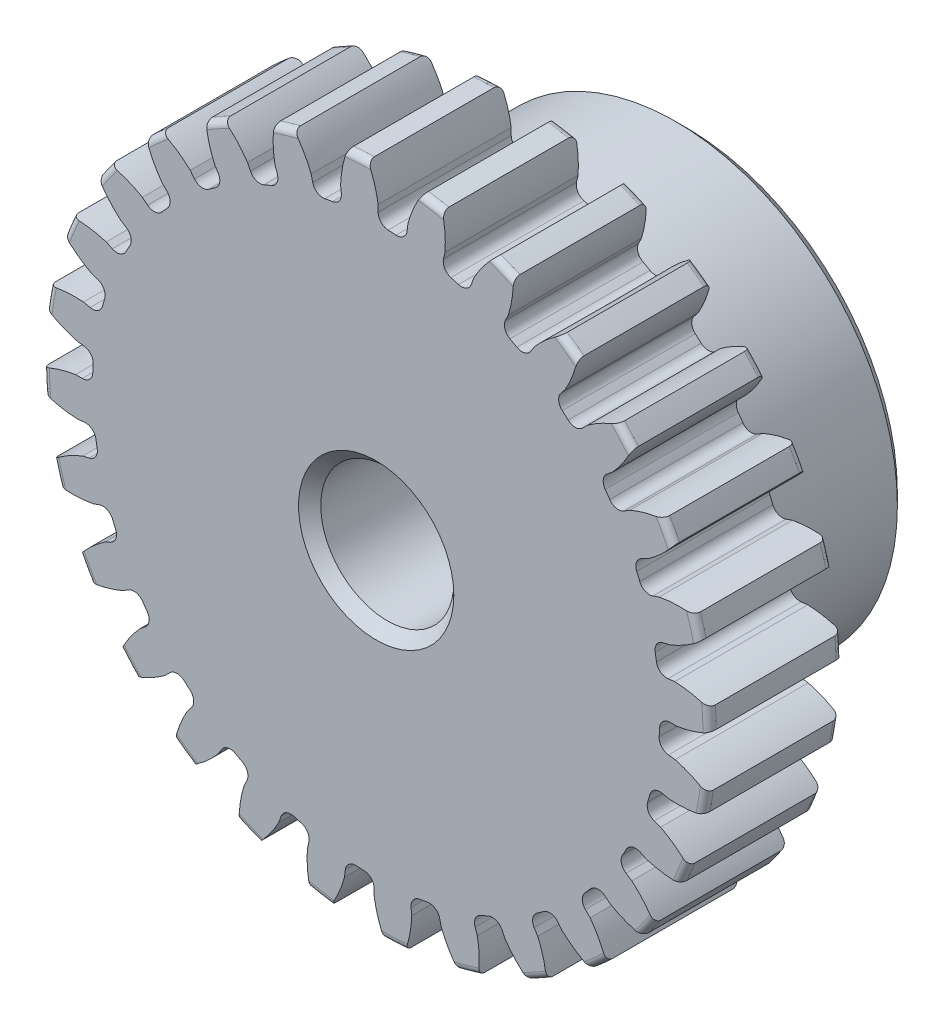
from build123d import *

# Parameters (mm, degrees)
SKETCH1_R                = 11.938
BOSS_EXTRUDE1_DEPTH      = 4.7625
SKETCH2_W                = 6.35
SKETCH2_H                = 7.9375
FILLET2_R                = 0.23876
CUT_EXTRUDE1_DEPTH       = 12.1125
FILLET1_R                = 0.37404675
CIRPATTERN1_COUNT        = 28
FILLET1_OF_CIRPATTERN1_R = 0.37404675
SKETCH5_R                = 2.38125
CUT_EXTRUDE2_DEPTH       = 12.1125
CHAMFER1_SIZE            = 0.396875


with BuildPart() as part:
    # Sketch1 → Boss-Extrude1 (new body)
    with BuildSketch(Plane.XY):
        Circle(SKETCH1_R)
    extrude(amount=-BOSS_EXTRUDE1_DEPTH)

    # Sketch2 → Revolve1 (revolve)
    with BuildSketch(Plane(origin=(0, 0, 0), x_dir=(0, 0, -1), z_dir=(1, 0, 0))):
        with Locations((7.9375, 3.96875)):
            Rectangle(SKETCH2_W, SKETCH2_H)
    revolve(axis=Axis((0, 0, -4.7625), (0, 0, -1)))

    # Fillet2
    fillet2_edges = [part.edges().sort_by_distance(p)[0] for p in [
        (-11.938, 0, 0),
        (-11.938, 0, -4.7625),
        (0, -7.9375, -4.7625),
    ]]
    fillet(fillet2_edges, radius=FILLET2_R)

    # Sketch4 → Cut-Extrude1 (cut, through all)
    with BuildSketch(Plane.XY):
        with BuildLine():
            Line((0.069806327, 10.758314184), (0.069806327, 10.1518225))
            ThreePointArc((0.069806327, 10.1518225), (0.569232014, 10.136091353), (1.067278737, 10.09580552))
            Line((1.067278737, 10.09580552), (1.135184419, 10.698483693))
            add(Edge.make_bspline(
                [(2.564809775, 12.853878952), (1.473078727, 11.956303136), (1.135184419, 10.698483693)],
                knots=[0, 0, 0, 1, 1, 1], degree=2))
            ThreePointArc((2.564809775, 12.853878952), (0.73493205, 13.086646941), (-1.10950154, 13.060224333))
            add(Edge.make_bspline(
                [(-1.10950154, 13.060224333), (-0.125131939, 12.046056933), (0.069806327, 10.758314184)],
                knots=[0, 0, 0, 1, 1, 1], degree=2))
        make_face()
    cut_extrude1 = extrude(amount=-CUT_EXTRUDE1_DEPTH, mode=Mode.SUBTRACT)

    # Fillet1
    fillet1_edges = [part.edges().sort_by_distance(p)[0] for p in [
        (1.067278737, 10.09580552, -2.38125),
        (0.069806327, 10.1518225, -2.38125),
    ]]
    fillet(fillet1_edges, radius=FILLET1_R)

    # CirPattern1: Cut-Extrude1 ×28 about axis
    cirpattern1_axis = Axis((0, 0, -4.7625), (0, 0, 1))
    for i in range(1, CIRPATTERN1_COUNT):
        add(cut_extrude1.rotate(cirpattern1_axis, i * 360 / CIRPATTERN1_COUNT), mode=Mode.SUBTRACT)

    # Fillet1 of CirPattern1
    fillet1_of_cirpattern1_edges = [part.edges().sort_by_distance(p)[0] for p in [
        (-1.206008243, 10.080174459, -2.38125),
        (-2.190936887, 9.912828484, -2.38125),
        (-3.418820933, 9.559081359, -2.38125),
        (-4.341817378, 9.176763856, -2.38125),
        (-5.460199666, 8.558656005, -2.38125),
        (-6.274981015, 7.980537968, -2.38125),
        (-7.227781188, 7.1290639, -2.38125),
        (-7.893490902, 6.384134584, -2.38125),
        (-8.632931581, 5.341990764, -2.38125),
        (-9.116188195, 4.467604033, -2.38125),
        (-9.605190736, 3.287047904, -2.38125),
        (-9.881761746, 2.327049161, -2.38125),
        (-10.09580552, 1.067278737, -2.38125),
        (-10.1518225, 0.069806327, -2.38125),
        (-10.080174459, -1.206008243, -2.38125),
        (-9.912828484, -2.190936887, -2.38125),
        (-9.559081359, -3.418820933, -2.38125),
        (-9.176763856, -4.341817378, -2.38125),
        (-8.558656005, -5.460199666, -2.38125),
        (-7.980537968, -6.274981015, -2.38125),
        (-7.1290639, -7.227781188, -2.38125),
        (-6.384134584, -7.893490902, -2.38125),
        (-5.341990764, -8.632931581, -2.38125),
        (-4.467604033, -9.116188195, -2.38125),
        (-3.287047904, -9.605190736, -2.38125),
        (-2.327049161, -9.881761746, -2.38125),
        (-1.067278737, -10.09580552, -2.38125),
        (-0.069806327, -10.1518225, -2.38125),
        (1.206008243, -10.080174459, -2.38125),
        (2.190936887, -9.912828484, -2.38125),
        (3.418820933, -9.559081359, -2.38125),
        (4.341817378, -9.176763856, -2.38125),
        (5.460199666, -8.558656005, -2.38125),
        (6.274981015, -7.980537968, -2.38125),
        (7.227781188, -7.1290639, -2.38125),
        (7.893490902, -6.384134584, -2.38125),
        (8.632931581, -5.341990764, -2.38125),
        (9.116188195, -4.467604033, -2.38125),
        (9.605190736, -3.287047904, -2.38125),
        (9.881761746, -2.327049161, -2.38125),
        (10.09580552, -1.067278737, -2.38125),
        (10.1518225, -0.069806327, -2.38125),
        (10.080174459, 1.206008243, -2.38125),
        (9.912828484, 2.190936887, -2.38125),
        (9.559081359, 3.418820933, -2.38125),
        (9.176763856, 4.341817378, -2.38125),
        (8.558656005, 5.460199666, -2.38125),
        (7.980537968, 6.274981015, -2.38125),
        (7.1290639, 7.227781188, -2.38125),
        (6.384134584, 7.893490902, -2.38125),
        (5.341990764, 8.632931581, -2.38125),
        (4.467604033, 9.116188195, -2.38125),
        (3.287047904, 9.605190736, -2.38125),
        (2.327049161, 9.881761746, -2.38125),
    ]]
    fillet(fillet1_of_cirpattern1_edges, radius=FILLET1_OF_CIRPATTERN1_R)

    # Sketch5 → Cut-Extrude2 (cut, through all)
    with BuildSketch(Plane.XY):
        Circle(SKETCH5_R)
    extrude(amount=-CUT_EXTRUDE2_DEPTH, mode=Mode.SUBTRACT)

    # Chamfer1
    chamfer1_edges = [part.edges().sort_by_distance(p)[0] for p in [
        (-2.38125, 0, -11.1125),
        (-2.38125, 0, 0),
        (0, -7.9375, -11.1125),
    ]]
    chamfer(chamfer1_edges, length=CHAMFER1_SIZE)


solid = part.part
